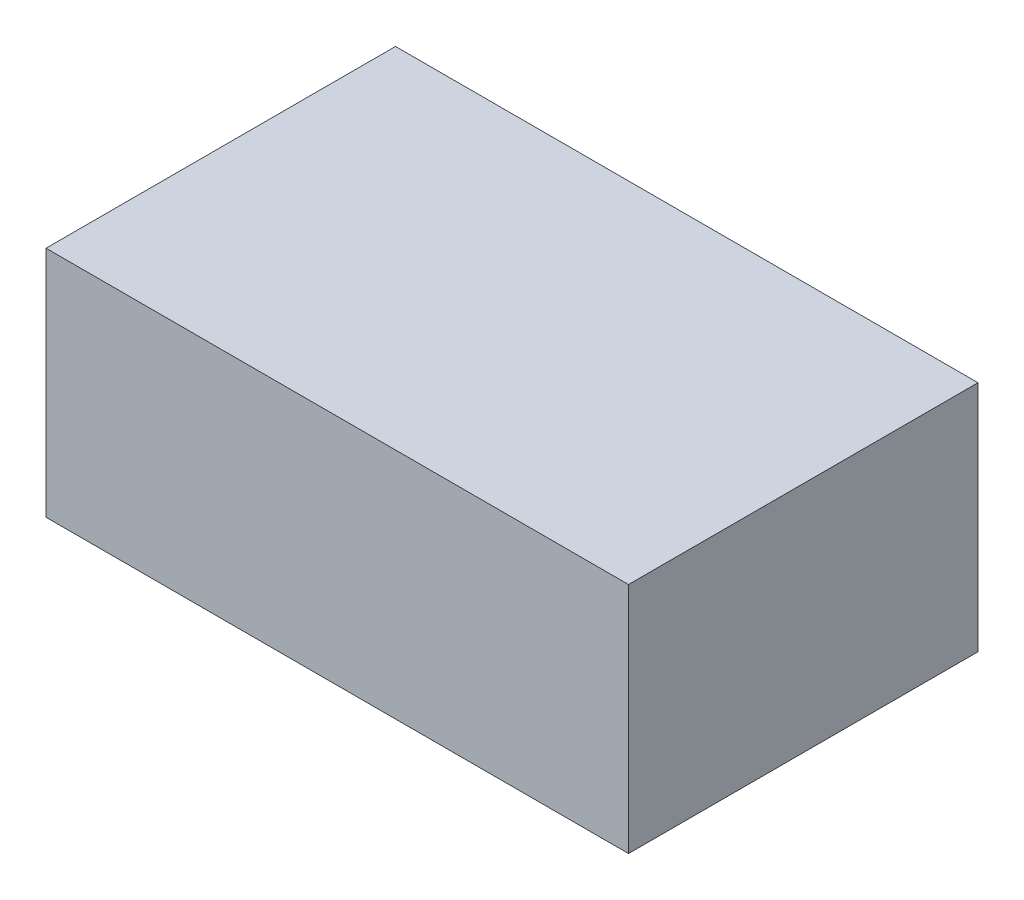
from build123d import *

# Parameters (mm, degrees)
SKETCH3_W           = 25
SKETCH3_H           = 15
BOSS_EXTRUDE1_DEPTH = 10
CUT_EXTRUDE1_DEPTH  = 2


with BuildPart() as part:
    # Sketch3 → Boss-Extrude1 (new body)
    with BuildSketch(Plane(origin=(0, 0, 0), x_dir=(1, 0, 0), z_dir=(0, 1, 0))):
        with Locations((15.783531292, 6.904865991)):
            Rectangle(SKETCH3_W, SKETCH3_H)
    extrude(amount=BOSS_EXTRUDE1_DEPTH)

    # Sketch4 → Cut-Extrude1 (cut)
    with BuildSketch(Plane.XZ):
        with BuildLine():
            Line((9.428221161, -5.210285602), (13.341179834, -10.757171936))
            Line((13.341179834, -10.757171936), (15.591615362, -13.947318093))
            Line((15.591615362, -13.947318093), (15.938880382, -14.404865991))
            Line((15.938880382, -14.404865991), (14.943009948, -14.404865991))
            Line((14.943009948, -14.404865991), (12.69257442, -11.214719833))
            Line((12.69257442, -11.214719833), (8.779615747, -5.667833499))
            ThreePointArc((8.779615747, -5.667833499), (6.372917751, -3.323604758), (3.283531292, -2.003265808))
            Line((3.283531292, -2.003265808), (3.283531292, -1.189966261))
            Line((3.283531292, -1.189966261), (3.456519377, -1.228595436))
            ThreePointArc((3.456519377, -1.228595436), (6.813253572, -2.6631932), (9.428221161, -5.210285602))
        make_face()
    extrude(amount=-CUT_EXTRUDE1_DEPTH, mode=Mode.SUBTRACT)


solid = part.part
